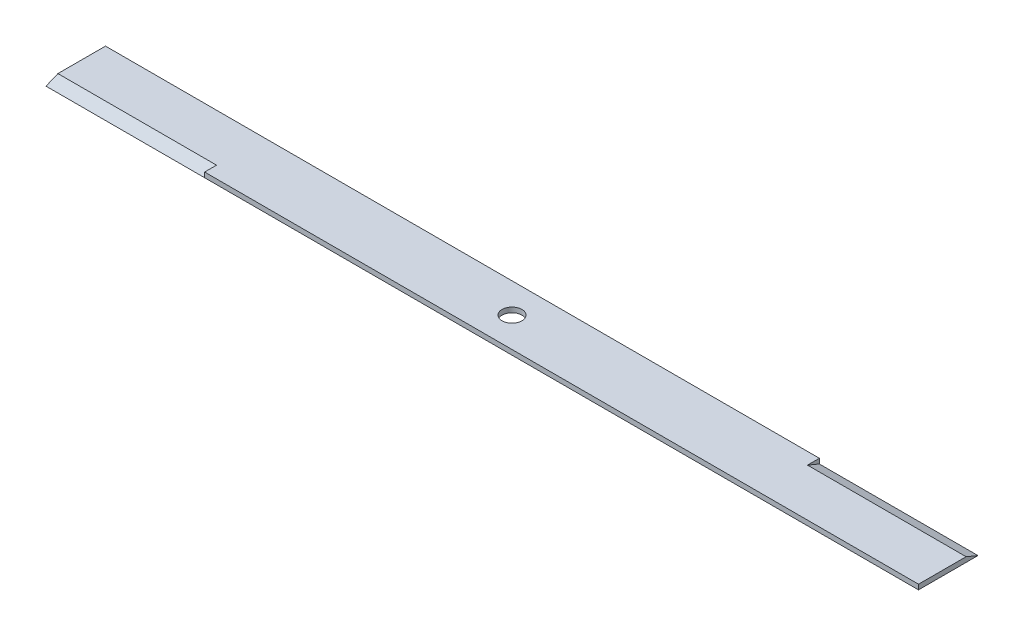
from build123d import *

# Parameters (mm, degrees)
SKETCH2_W            = 558.8
SKETCH2_H            = 38.1
SKETCH2_R            = 6.35
MOWER_BLADE_DEPTH    = 3.175
CUTTING_EDGE_1_DEPTH = 101.6
CUTTING_EDGE_2_DEPTH = 101.6


with BuildPart() as part:
    # Sketch2 → Mower Blade (new body)
    with BuildSketch(Plane(origin=(0, 0, 0), x_dir=(1, 0, 0), z_dir=(0, 1, 0))):
        Rectangle(SKETCH2_W, SKETCH2_H)
        Circle(SKETCH2_R, mode=Mode.SUBTRACT)
    extrude(amount=MOWER_BLADE_DEPTH)

    # Sketch3 → Cutting Edge #1 (cut)
    with BuildSketch(Plane(origin=(279.4, 0, 0), x_dir=(0, 0, -1), z_dir=(1, 0, 0))):
        Polygon((19.05, 0), (11.43, 3.175), (19.05, 3.175), align=None)
    extrude(amount=-CUTTING_EDGE_1_DEPTH, mode=Mode.SUBTRACT)

    # Sketch4 → Cutting Edge #2 (cut)
    with BuildSketch(Plane.ZY.offset(279.4)):
        Polygon((19.05, 0), (11.43, 3.175), (19.05, 3.175), align=None)
    extrude(amount=-CUTTING_EDGE_2_DEPTH, mode=Mode.SUBTRACT)


solid = part.part
